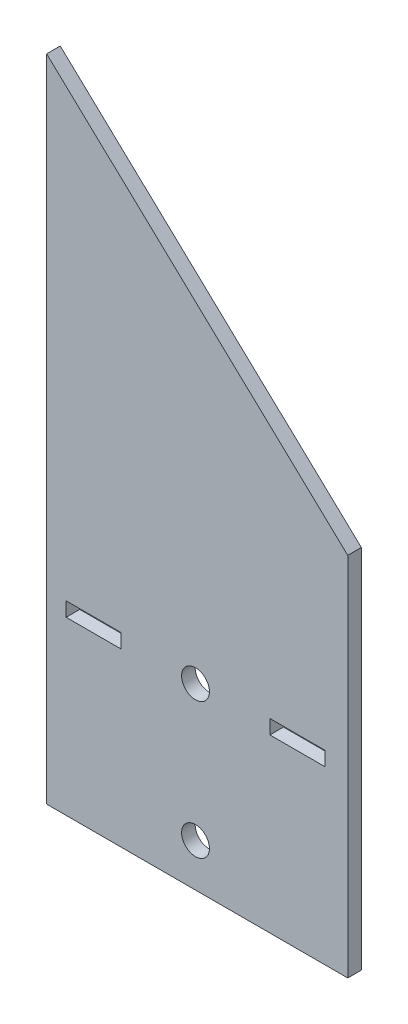
from build123d import *

# Parameters (mm, degrees)
SKETCH_1_R      = 2.05
SKETCH_1_W      = 8.1
SKETCH_1_H      = 2.1
EXTRUDE_1_DEPTH = 2


with BuildPart() as part:
    # 草图1 → 凸台-拉伸1 (new body)
    with BuildSketch(Plane.XY):
        Polygon((-21.91868524, -9.787808432), (-21.91868524, -41.714516484), (22.419428501, -41.714516484), (22.419428501, -9.787808432), (22.419428501, 12.188083696), (-21.91868524, 53.968649146), align=None)
        with Locations((0, -35.4)):
            Circle(SKETCH_1_R, mode=Mode.SUBTRACT)
        with Locations((0, -15.4)):
            Circle(SKETCH_1_R, mode=Mode.SUBTRACT)
        with Locations((-15, -15.4)):
            Rectangle(SKETCH_1_W, SKETCH_1_H, mode=Mode.SUBTRACT)
        with Locations((15, -15.4)):
            Rectangle(SKETCH_1_W, SKETCH_1_H, mode=Mode.SUBTRACT)
    extrude(amount=EXTRUDE_1_DEPTH)


solid = part.part
